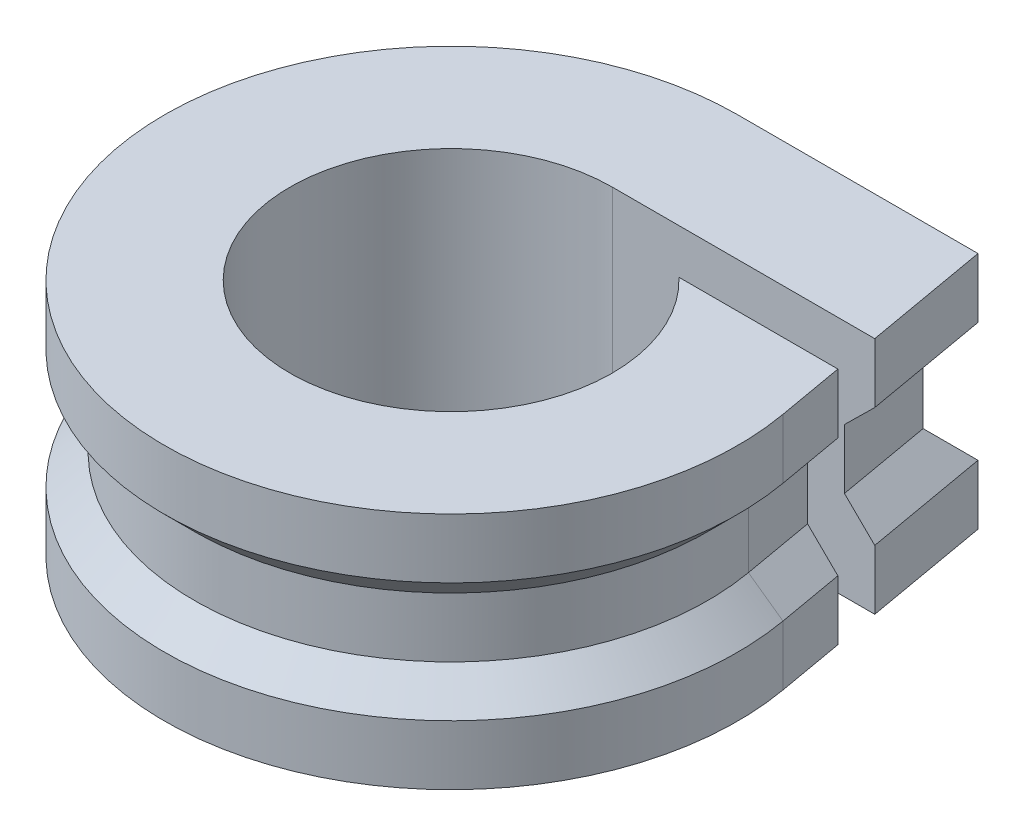
from build123d import *

# Parameters (mm, degrees)
BOSS_EXTRUDE1_DEPTH = 3
CHAMFER1_SIZE       = 1
BOSS_EXTRUDE2_DEPTH = 1


with BuildPart() as part:
    # Sketch1 → Boss-Extrude1 (new body)
    with BuildSketch(Plane(origin=(0, 0, 0), x_dir=(1, 0, 0), z_dir=(0, 1, 0))):
        with BuildLine():
            Line((8.055356459, 9.6), (0, 9.6))
            ThreePointArc((0, 9.6), (-6.170761053, -7.354026654), (9.454154429, 1.667022506))
            Line((9.454154429, 1.667022506), (9.060420249, 3.9))
            Line((9.060420249, 3.9), (3.734969879, 3.9))
            ThreePointArc((3.734969879, 3.9), (4.96632849, 2.120278596), (5.4, 0))
            ThreePointArc((5.4, 0), (-3.818376618, -3.818376618), (0, 5.4))
            Line((0, 5.4), (8.795929778, 5.4))
            Line((8.795929778, 5.4), (8.055356459, 9.6))
        make_face()
    extrude(amount=BOSS_EXTRUDE1_DEPTH)

    # Chamfer1
    chamfer1_edges = [part.edges().sort_by_distance(p)[0] for p in [
        (-6.170761053, 3, 7.354026654),
        (9.257287339, 3, -2.783511253),
        (8.425643119, 3, -7.5),
        (4.02767823, 3, -9.6),
    ]]
    chamfer(chamfer1_edges, length=CHAMFER1_SIZE)

    # Sketch3 → Boss-Extrude2 (add)
    with BuildSketch(Plane(origin=(0, 3, 0), x_dir=(1, 0, 0), z_dir=(0, 1, 0))):
        with BuildLine():
            Line((0, 5.4), (7.780503166, 5.4))
            Line((7.780503166, 5.4), (7.216256828, 8.6))
            Line((7.216256828, 8.6), (0, 8.6))
            ThreePointArc((0, 8.6), (-5.527973443, -6.587982211), (8.469346676, 1.493374328))
            Line((8.469346676, 1.493374328), (8.044993637, 3.9))
            Line((8.044993637, 3.9), (3.734969879, 3.9))
            ThreePointArc((3.734969879, 3.9), (-2.01246118, -5.010987927), (0, 5.4))
        make_face()
    extrude(amount=BOSS_EXTRUDE2_DEPTH)

    # Mirror1: part across plane


with BuildPart() as part_1:
    add(part.part)
    add(part.part.mirror(Plane.ZX.offset(4)))


solid = part_1.part
